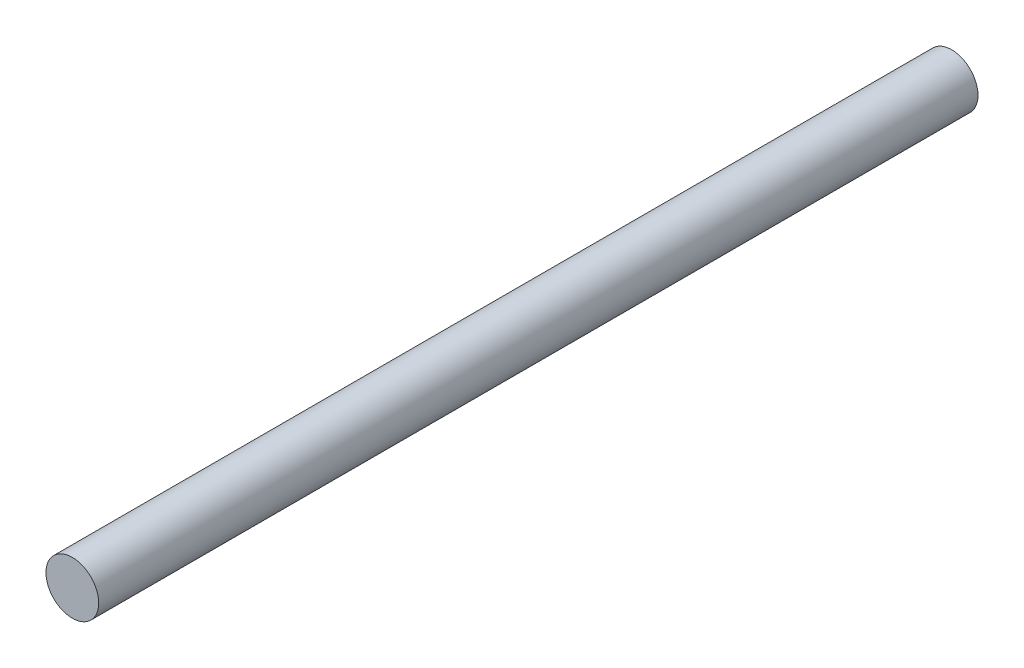
from build123d import *

# Parameters (mm, degrees)
SKETCH_1_R      = 15
EXTRUDE_1_DEPTH = 500


with BuildPart() as part:
    # 草图1 → 凸台-拉伸1 (new body)
    with BuildSketch(Plane.XY):
        with Locations((-142.440268853, 390.912229572)):
            Circle(SKETCH_1_R)
    extrude(amount=EXTRUDE_1_DEPTH)


solid = part.part
